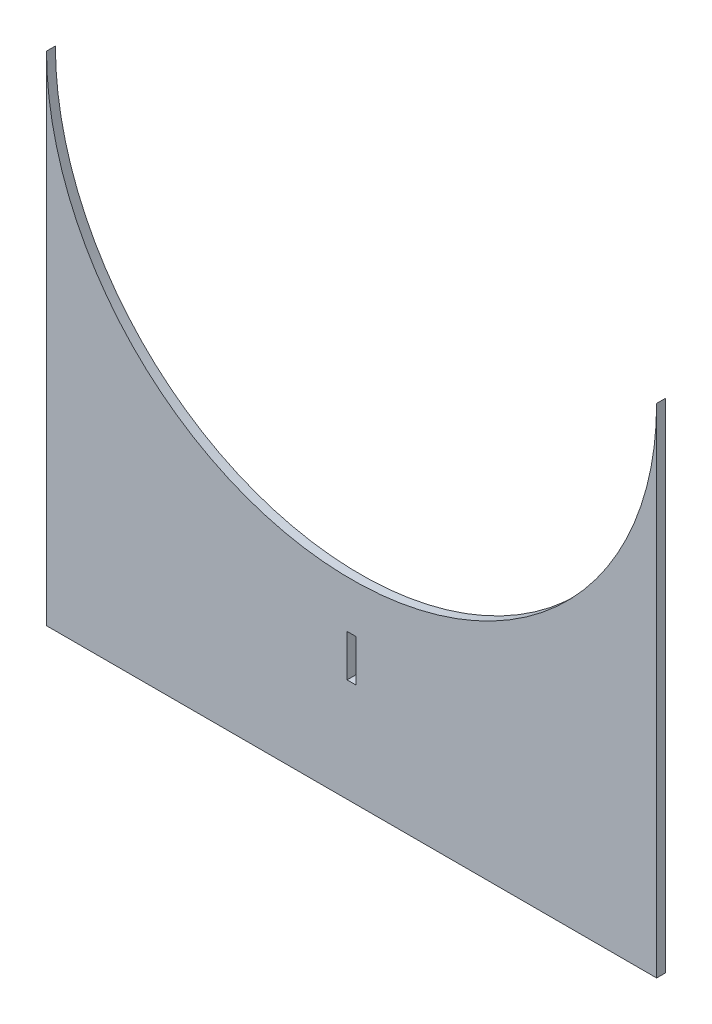
from build123d import *

# Parameters (mm, degrees)
BOSS_EXTRUDE1_DEPTH = 3.175
SKETCH2_W           = 3.175
SKETCH2_H           = 15
CUT_EXTRUDE1_DEPTH  = 3.175


with BuildPart() as part:
    # Sketch1 → Boss-Extrude1 (new body)
    with BuildSketch(Plane.XY):
        with BuildLine():
            ThreePointArc((-109, 88.9), (0, -20.1), (109, 88.9))
            Line((109, 88.9), (109, -88.9))
            Line((109, -88.9), (-109, -88.9))
            Line((-109, -88.9), (-109, 88.9))
        make_face()
    extrude(amount=BOSS_EXTRUDE1_DEPTH)

    # Sketch2 → Cut-Extrude1 (cut)
    with BuildSketch(Plane(origin=(0, 0, 0), x_dir=(-1, 0, 0), z_dir=(0, 0, -1))):
        with Locations((0, -44.45)):
            Rectangle(SKETCH2_W, SKETCH2_H)
    extrude(amount=-CUT_EXTRUDE1_DEPTH, mode=Mode.SUBTRACT)


solid = part.part
